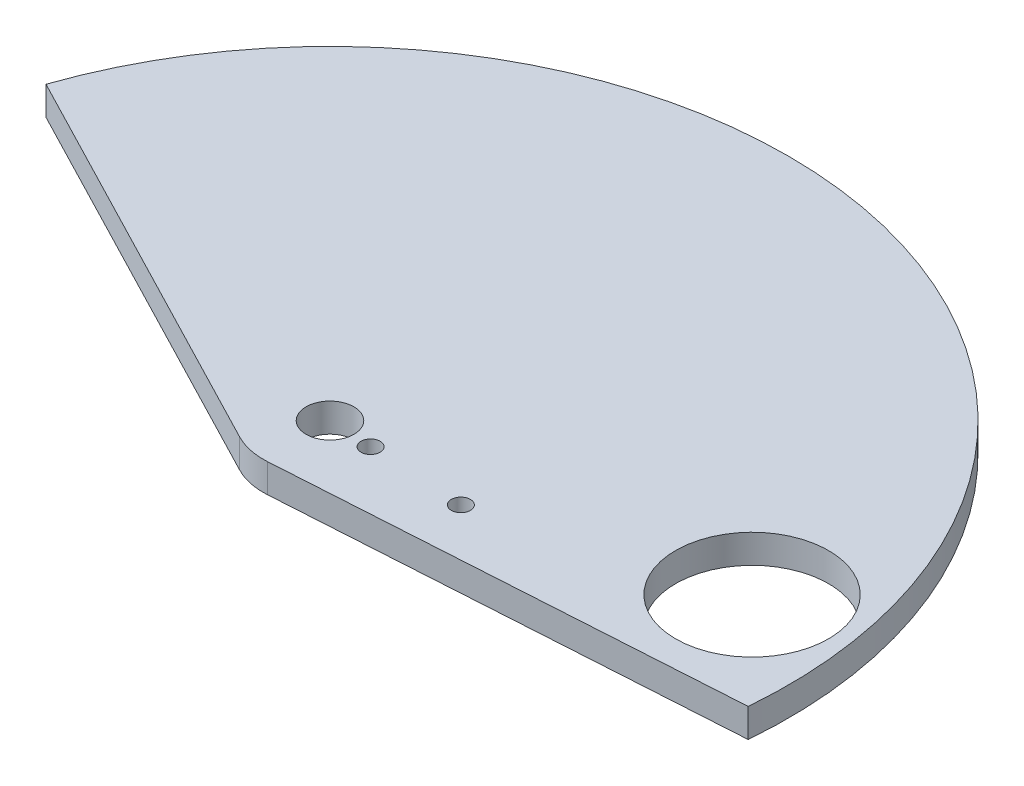
from build123d import *

# Parameters (mm, degrees)
SKETCH1_R           = 8
SKETCH1_R_2         = 2.5
SKETCH1_R_3         = 1
BOSS_EXTRUDE1_DEPTH = 3


with BuildPart() as part:
    # Sketch1 → Boss-Extrude1 (new body)
    with BuildSketch(Plane(origin=(0, 0, 0), x_dir=(1, 0, 0), z_dir=(0, 1, 0))):
        with BuildLine():
            Line((-38.306620426, 21.610257702), (3.777430911, -0.214100777))
            ThreePointArc((3.777430911, -0.214100777), (5.555187673, -0.8492713), (7.438028309, -0.986281643))
            Line((7.438028309, -0.986281643), (54.75155699, 1.980198384))
            ThreePointArc((54.75155699, 1.980198384), (16.890866287, 52.888599511), (-38.306620426, 21.610257702))
        make_face()
        with Locations((44.834484792, 12.301412972)):
            Circle(SKETCH1_R, mode=Mode.SUBTRACT)
        with Locations((7, 6)):
            Circle(SKETCH1_R_2, mode=Mode.SUBTRACT)
        with Locations((21.478261726, 5.20631405)):
            Circle(SKETCH1_R_3, mode=Mode.SUBTRACT)
        with Locations((11.493253639, 5.753683671)):
            Circle(SKETCH1_R_3, mode=Mode.SUBTRACT)
    extrude(amount=BOSS_EXTRUDE1_DEPTH)


solid = part.part
